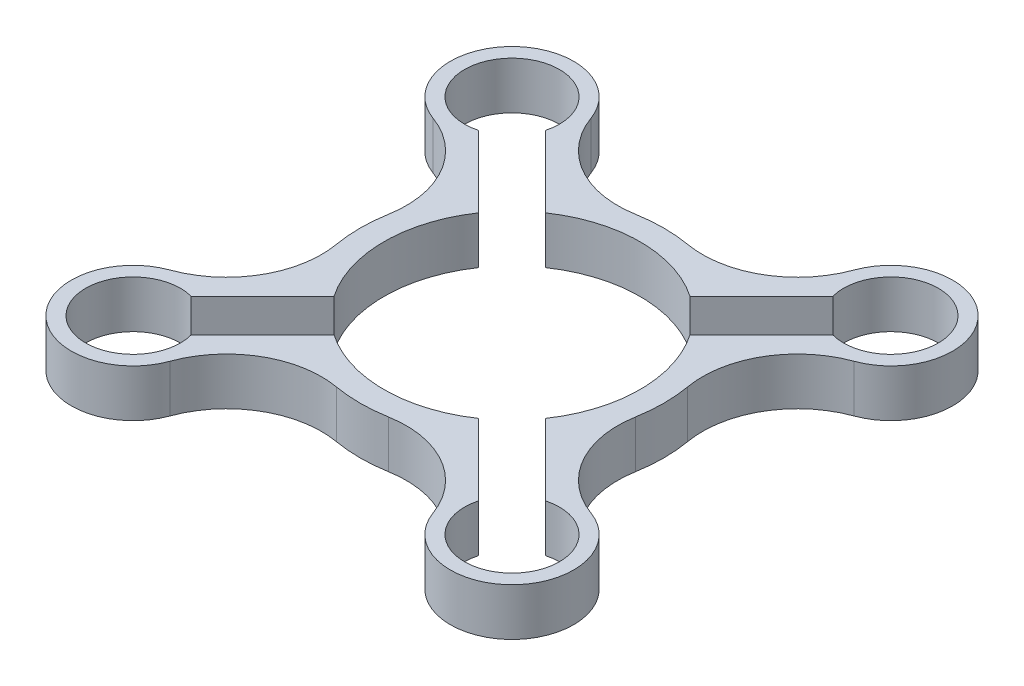
from build123d import *

# Parameters (mm, degrees)
BOSS_EXTRUDE1_DEPTH = 10


with BuildPart() as part:
    # Sketch1 → Boss-Extrude1 (new body)
    with BuildSketch(Plane(origin=(0, 0, 0), x_dir=(1, 0, 0), z_dir=(0, 1, 0))):
        with BuildLine():
            ThreePointArc((-31.523820357, 5.499886369), (-32, 0), (-31.523820357, -5.499886369))
            ThreePointArc((-31.523820357, -5.499886369), (-33.916662735, -18.956279365), (-44.393071751, -27.733810979))
            ThreePointArc((-44.393071751, -27.733810979), (-49.143921292, -49.143921292), (-27.733810979, -44.393071751))
            ThreePointArc((-27.733810979, -44.393071751), (-18.956279365, -33.916662735), (-5.499886369, -31.523820357))
            ThreePointArc((-5.499886369, -31.523820357), (0, -32), (5.499886369, -31.523820357))
            ThreePointArc((5.499886369, -31.523820357), (18.956279365, -33.916662735), (27.733810979, -44.393071751))
            ThreePointArc((27.733810979, -44.393071751), (49.143921292, -49.143921292), (44.393071751, -27.733810979))
            ThreePointArc((44.393071751, -27.733810979), (33.916662735, -18.956279365), (31.523820357, -5.499886369))
            ThreePointArc((31.523820357, -5.499886369), (32, 0), (31.523820357, 5.499886369))
            ThreePointArc((31.523820357, 5.499886369), (33.916662735, 18.956279365), (44.393071751, 27.733810979))
            ThreePointArc((44.393071751, 27.733810979), (49.143921292, 49.143921292), (27.733810979, 44.393071751))
            ThreePointArc((27.733810979, 44.393071751), (18.956279365, 33.916662735), (5.499886369, 31.523820357))
            ThreePointArc((5.499886369, 31.523820357), (0, 32), (-5.499886369, 31.523820357))
            ThreePointArc((-5.499886369, 31.523820357), (-18.956279365, 33.916662735), (-27.733810979, 44.393071751))
            ThreePointArc((-27.733810979, 44.393071751), (-49.143921292, 49.143921292), (-44.393071751, 27.733810979))
            ThreePointArc((-44.393071751, 27.733810979), (-33.916662735, 18.956279365), (-31.523820357, 5.499886369))
        make_face()
        with BuildLine():
            Line((-37.363342686, 30.292274874), (-22.297196945, 15.226129133))
            ThreePointArc((-22.297196945, 15.226129133), (-27, 0), (-22.297196945, -15.226129133))
            Line((-22.297196945, -15.226129133), (-37.363342686, -30.292274874))
            ThreePointArc((-37.363342686, -30.292274874), (-47.022600949, -47.022600949), (-30.292274874, -37.363342686))
            Line((-30.292274874, -37.363342686), (-15.226129133, -22.297196945))
            ThreePointArc((-15.226129133, -22.297196945), (0, -27), (15.226129133, -22.297196945))
            Line((15.226129133, -22.297196945), (30.292274874, -37.363342686))
            ThreePointArc((30.292274874, -37.363342686), (47.022600949, -47.022600949), (37.363342686, -30.292274874))
            Line((37.363342686, -30.292274874), (22.297196945, -15.226129133))
            ThreePointArc((22.297196945, -15.226129133), (27, 0), (22.297196945, 15.226129133))
            Line((22.297196945, 15.226129133), (37.363342686, 30.292274874))
            ThreePointArc((37.363342686, 30.292274874), (47.022600949, 47.022600949), (30.292274874, 37.363342686))
            Line((30.292274874, 37.363342686), (15.226129133, 22.297196945))
            ThreePointArc((15.226129133, 22.297196945), (0, 27), (-15.226129133, 22.297196945))
            Line((-15.226129133, 22.297196945), (-30.292274874, 37.363342686))
            ThreePointArc((-30.292274874, 37.363342686), (-47.022600949, 47.022600949), (-37.363342686, 30.292274874))
        make_face(mode=Mode.SUBTRACT)
    extrude(amount=BOSS_EXTRUDE1_DEPTH)


solid = part.part
